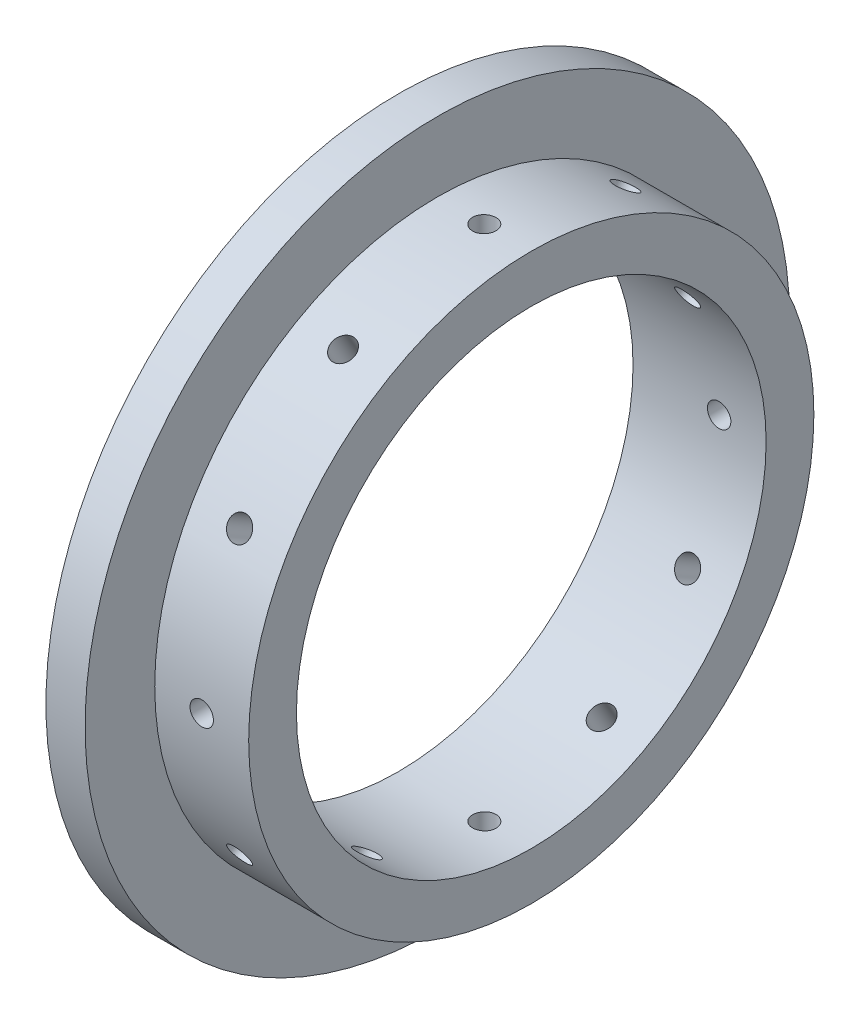
from build123d import *

# Parameters (mm, degrees)
SKETCH1_R           = 57.15
SKETCH1_R_2         = 38.1
BOSS_EXTRUDE1_DEPTH = 6.35
SKETCH2_R           = 45.847
SKETCH2_R_2         = 38.1
BOSS_EXTRUDE2_DEPTH = 15.24
SKETCH4_R           = 1.89865
CUT_EXTRUDE1_DEPTH  = 11.43
CIRPATTERN1_COUNT   = 12


with BuildPart() as part:
    # Sketch1 → Boss-Extrude1 (new body)
    with BuildSketch(Plane(origin=(0, 0, 0), x_dir=(0, 0, -1), z_dir=(1, 0, 0))):
        Circle(SKETCH1_R)
        Circle(SKETCH1_R_2, mode=Mode.SUBTRACT)
    extrude(amount=BOSS_EXTRUDE1_DEPTH)

    # Sketch2 → Boss-Extrude2 (add)
    with BuildSketch(Plane(origin=(6.35, 0, 0), x_dir=(0, 0, -1), z_dir=(1, 0, 0))):
        Circle(SKETCH2_R)
        Circle(SKETCH2_R_2, mode=Mode.SUBTRACT)
    extrude(amount=BOSS_EXTRUDE2_DEPTH)

    # Sketch4 → Cut-Extrude1 (cut)
    with BuildSketch(Plane(origin=(0, 0, -45.847), x_dir=(-1, 0, 0), z_dir=(0, 0, -1))):
        with Locations((-13.97, 0)):
            Circle(SKETCH4_R)
    cut_extrude1 = extrude(amount=-CUT_EXTRUDE1_DEPTH, mode=Mode.SUBTRACT)

    # CirPattern1: Cut-Extrude1 ×12 about axis
    cirpattern1_axis = Axis((0, 0, 0), (1, 0, 0))
    for i in range(1, CIRPATTERN1_COUNT):
        add(cut_extrude1.rotate(cirpattern1_axis, i * 360 / CIRPATTERN1_COUNT), mode=Mode.SUBTRACT)


solid = part.part
